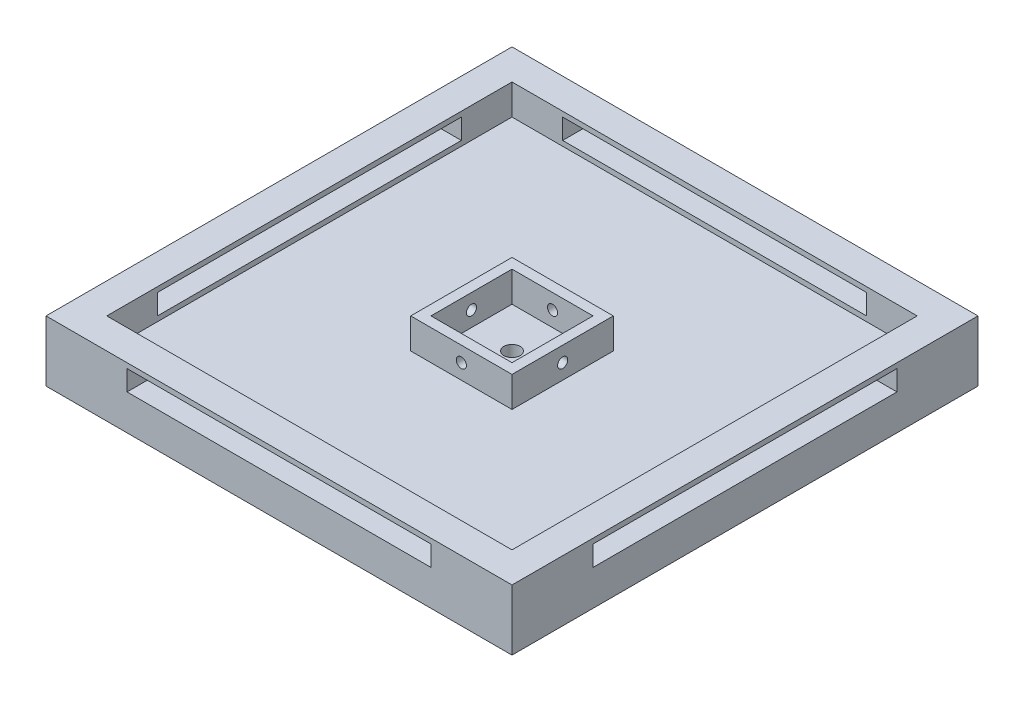
from build123d import *

# Parameters (mm, degrees)
SKETCH1_W               = 40
SKETCH1_H               = 40
BOSS_EXTRUDE1_DEPTH     = 3
SKETCH2_W               = 40
SKETCH2_H               = 6
BOSS_EXTRUDE2_DEPTH     = 3
SKETCH4_W               = 43
SKETCH4_H               = 6
BOSS_EXTRUDE3_DEPTH     = 3
SKETCH5_W               = 43
SKETCH5_H               = 6
BOSS_EXTRUDE4_DEPTH     = 3
SKETCH6_W               = 46
SKETCH6_H               = 6
BOSS_EXTRUDE5_DEPTH     = 3
SKETCH7_W               = 30
SKETCH7_H               = 2
CUT_EXTRUDE1_DEPTH      = 3
MIRROR2_COPY_1_SKETCH_W = 30
MIRROR2_COPY_1_SKETCH_H = 2
MIRROR2_COPY_1_DEPTH    = 3
SKETCH8_W               = 10
SKETCH8_H               = 10
SKETCH8_W_2             = 7.999655552
SKETCH8_H_2             = 7.999655552
BOSS_EXTRUDE6_DEPTH     = 3
SKETCH9_R               = 0.8
CUT_EXTRUDE2_DEPTH      = 3
SKETCH10_R              = 0.5
CUT_EXTRUDE3_DEPTH      = 10


with BuildPart() as part:
    # Sketch1 → Boss-Extrude1 (new body)
    with BuildSketch(Plane(origin=(0, 0, 0), x_dir=(1, 0, 0), z_dir=(0, 1, 0))):
        with Locations((-20, -20)):
            Rectangle(SKETCH1_W, SKETCH1_H)
    extrude(amount=BOSS_EXTRUDE1_DEPTH)



with BuildPart() as body_2:
    # Sketch2 → Boss-Extrude2 (new body)
    with BuildSketch(Plane(origin=(0, 0, 0), x_dir=(0, 0, -1), z_dir=(1, 0, 0))):
        with Locations((-20, 3)):
            Rectangle(SKETCH2_W, SKETCH2_H)
    extrude(amount=BOSS_EXTRUDE2_DEPTH)


with BuildPart() as part_1:
    add(part.part)

    add(body_2.part)  # Boss-Extrude3 merges body 2
    # Sketch4 → Boss-Extrude3 (add)
    with BuildSketch(Plane.XY.offset(40)):
        with Locations((-18.5, 3)):
            Rectangle(SKETCH4_W, SKETCH4_H)
    extrude(amount=BOSS_EXTRUDE3_DEPTH)

    # Sketch5 → Boss-Extrude4 (add)
    with BuildSketch(Plane(origin=(0, 0, 0), x_dir=(-1, 0, 0), z_dir=(0, 0, -1))):
        with Locations((18.5, 3)):
            Rectangle(SKETCH5_W, SKETCH5_H)
    extrude(amount=BOSS_EXTRUDE4_DEPTH)

    # Sketch6 → Boss-Extrude5 (add)
    with BuildSketch(Plane.ZY.offset(40)):
        with Locations((20, 3)):
            Rectangle(SKETCH6_W, SKETCH6_H)
    extrude(amount=BOSS_EXTRUDE5_DEPTH)

    # Sketch7 → Cut-Extrude1 (cut)
    with BuildSketch(Plane.ZY):
        with Locations((20, 4.5)):
            Rectangle(SKETCH7_W, SKETCH7_H)
    cut_extrude1 = extrude(amount=-CUT_EXTRUDE1_DEPTH, mode=Mode.SUBTRACT)

    # Mirror1: Cut-Extrude1 across plane
    add(cut_extrude1.mirror(Plane(origin=(0, 0, 0), x_dir=(-0.707106781, 0, 0.707106781), z_dir=(0.707106781, 0, 0.707106781))), mode=Mode.SUBTRACT)

    # Mirror2: Cut-Extrude1 across plane
    add(cut_extrude1.mirror(Plane(origin=(-20, 0, 20), x_dir=(0.707106781, 0, 0.707106781), z_dir=(0.707106781, 0, -0.707106781))), mode=Mode.SUBTRACT)

    # Mirror2 copy 1 sketch → Mirror2 copy 1 (cut)
    with BuildSketch(Plane(origin=(-40, 0, 40), x_dir=(0, 0, -1), z_dir=(1, 0, 0))):
        with Locations((20, 4.5)):
            Rectangle(MIRROR2_COPY_1_SKETCH_W, MIRROR2_COPY_1_SKETCH_H)
    extrude(amount=-MIRROR2_COPY_1_DEPTH, mode=Mode.SUBTRACT)

    # Sketch8 → Boss-Extrude6 (add)
    with BuildSketch(Plane(origin=(0, 3, 0), x_dir=(1, 0, 0), z_dir=(0, 1, 0))):
        with Locations((-20, -20)):
            Rectangle(SKETCH8_W, SKETCH8_H)
        with Locations((-20, -20)):
            Rectangle(SKETCH8_W_2, SKETCH8_H_2, mode=Mode.SUBTRACT)
    extrude(amount=BOSS_EXTRUDE6_DEPTH)

    # Sketch9 → Cut-Extrude2 (cut)
    with BuildSketch(Plane(origin=(0, 3, 0), x_dir=(1, 0, 0), z_dir=(0, 1, 0))):
        with Locations((-20, -20)):
            Circle(SKETCH9_R)
    extrude(amount=-CUT_EXTRUDE2_DEPTH, mode=Mode.SUBTRACT)

    # Sketch10 → Cut-Extrude3 (cut)
    with BuildSketch(Plane.ZY.offset(25)):
        with Locations((20, 4.5)):
            Circle(SKETCH10_R)
    cut_extrude3 = extrude(amount=-CUT_EXTRUDE3_DEPTH, mode=Mode.SUBTRACT)

    # Mirror3: Cut-Extrude3 across plane
    add(cut_extrude3.mirror(Plane(origin=(-20, 0, 20), x_dir=(0.707106781, 0, 0.707106781), z_dir=(0.707106781, 0, -0.707106781))), mode=Mode.SUBTRACT)


solid = part_1.part
